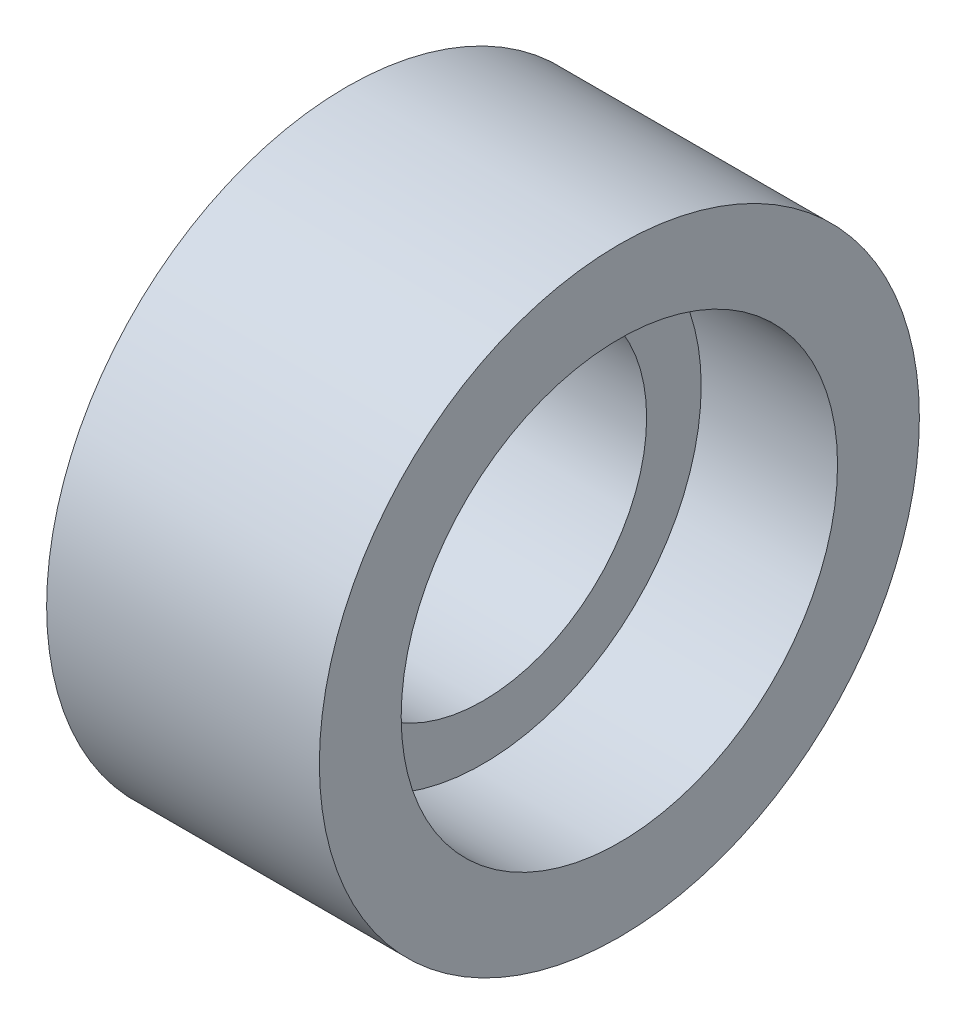
from build123d import *


with BuildPart() as part:
    # Esquisse1 → Révolution1 (revolve)
    with BuildSketch(Plane.XY):
        Polygon((10.925936703, 6), (10.925936703, 11), (20.925936703, 11), (20.925936703, 8), (15.925936703, 8), (15.925936703, 6), align=None)
    revolve(axis=Axis((0, 0, 0), (1, 0, 0)))


solid = part.part
